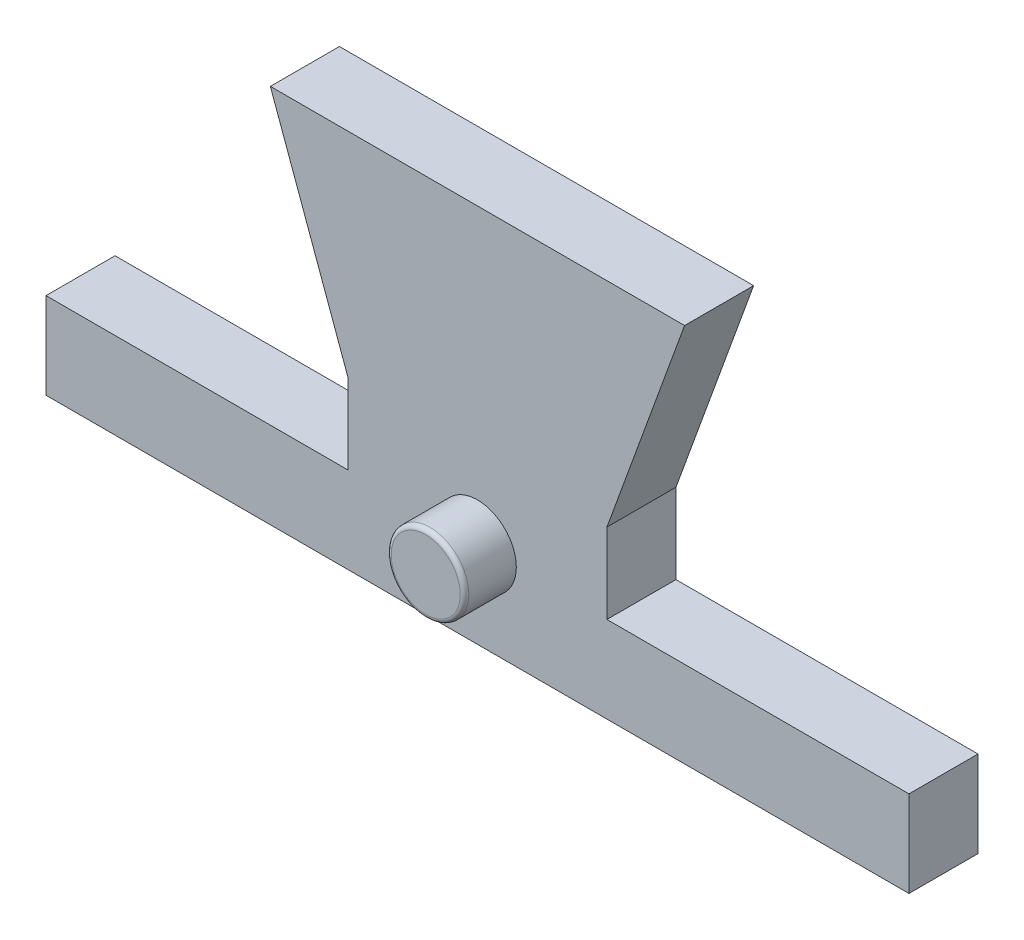
from build123d import *

# Parameters (mm, degrees)
BOSS_EXTRUDE1_DEPTH      = 4
SKETCH2_R                = 2.25
BOSS_EXTRUDE2_DEPTH      = 3
BOSS_EXTRUDE2_DEPTH_BACK = 7
FILLET1_R                = 0.25


with BuildPart() as part:
    # Sketch1 → Boss-Extrude1 (new body)
    with BuildSketch(Plane.XY):
        Polygon((-50, 0), (0, 0), (0, 5), (-17.5, 5), (-17.5, 9.636351612), (-13, 22), (-37, 22), (-32.5, 9.636351612), (-32.5, 5), (-50, 5), align=None)
    extrude(amount=BOSS_EXTRUDE1_DEPTH)

    # Sketch2 → Boss-Extrude2 (add, two sides)
    with BuildSketch(Plane.XY.offset(4)) as boss_extrude2_sk:
        with Locations((-25, 5)):
            Circle(SKETCH2_R)
    extrude(amount=BOSS_EXTRUDE2_DEPTH)
    extrude(boss_extrude2_sk.sketch, amount=-BOSS_EXTRUDE2_DEPTH_BACK)

    # Fillet1
    fillet1_edges = [part.edges().sort_by_distance(p)[0] for p in [
        (-27.25, 5, -3),
        (-27.25, 5, 7),
    ]]
    fillet(fillet1_edges, radius=FILLET1_R)


solid = part.part
